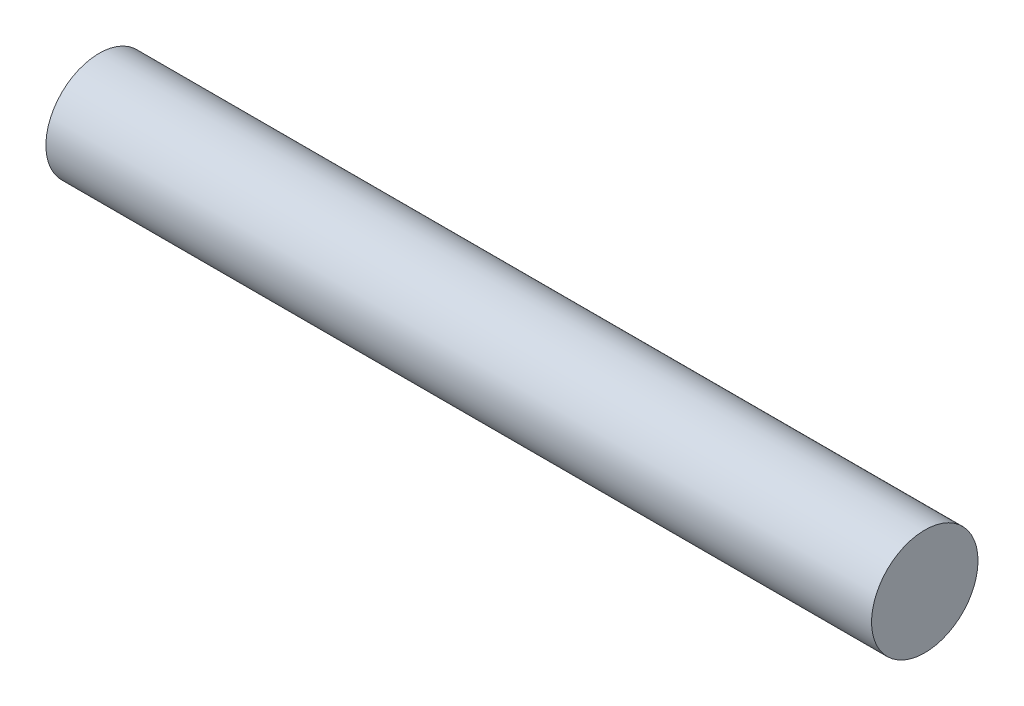
from build123d import *

# Parameters (mm, degrees)
BOSS_EXTRUDE1_DEPTH      = 5.315
BOSS_EXTRUDE1_DEPTH_BACK = 5.315
SKETCH2_R                = 0.685


with BuildPart() as part:
    # Sketch2 → Boss-Extrude1 (new, two sides: drawn at the far end of the back side and taken through both)
    with BuildSketch(Plane(origin=(0, 0, 0), x_dir=(0, 0, -1), z_dir=(1, 0, 0)).offset(-BOSS_EXTRUDE1_DEPTH_BACK)):
        Circle(SKETCH2_R)
    extrude(amount=BOSS_EXTRUDE1_DEPTH + BOSS_EXTRUDE1_DEPTH_BACK)


solid = part.part
